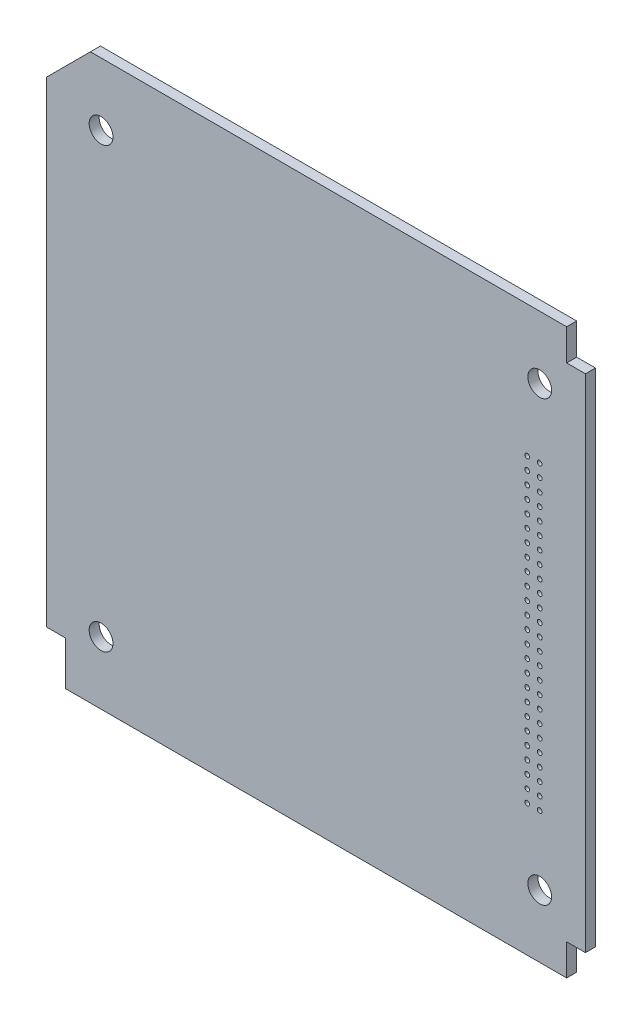
from build123d import *

# Parameters (mm, degrees)
SKETCH1_R           = 1.9
SKETCH1_R_2         = 0.375
SKETCH1_R_3         = 0.383755901
SKETCH1_R_4         = 0.384163196
SKETCH1_R_5         = 0.380771211
SKETCH1_R_6         = 0.377379225
SKETCH1_R_7         = 0.380832793
BOSS_EXTRUDE1_DEPTH = 1.6
SKETCH_1_W          = 3
SKETCH_1_H          = 7
CUT_EXTRUDE_1_DEPTH = 10


with BuildPart() as part:
    # Sketch1 → Boss-Extrude1 (new body)
    with BuildSketch(Plane.XY):
        Polygon((-3, 0), (-86, 0), (-86, -90), (-3, -90), (-3, -85), (0, -85), (0, -5), (-3, -5), align=None)
        with Locations((-7.3, -10)):
            Circle(SKETCH1_R, mode=Mode.SUBTRACT)
        with Locations((-77.3, -10)):
            Circle(SKETCH1_R, mode=Mode.SUBTRACT)
        with Locations((-77.3, -80)):
            Circle(SKETCH1_R, mode=Mode.SUBTRACT)
        with Locations((-7.3, -80)):
            Circle(SKETCH1_R, mode=Mode.SUBTRACT)
        with Locations((-9.3, -69)):
            Circle(SKETCH1_R_2, mode=Mode.SUBTRACT)
        with Locations((-7.3, -69)):
            Circle(SKETCH1_R_2, mode=Mode.SUBTRACT)
        with Locations((-7.3, -67)):
            Circle(SKETCH1_R_2, mode=Mode.SUBTRACT)
        with Locations((-9.3, -67)):
            Circle(SKETCH1_R_2, mode=Mode.SUBTRACT)
        with Locations((-9.3, -65)):
            Circle(SKETCH1_R_2, mode=Mode.SUBTRACT)
        with Locations((-7.3, -65)):
            Circle(SKETCH1_R_2, mode=Mode.SUBTRACT)
        with Locations((-7.3, -63)):
            Circle(SKETCH1_R_2, mode=Mode.SUBTRACT)
        with Locations((-9.3, -63)):
            Circle(SKETCH1_R_3, mode=Mode.SUBTRACT)
        with Locations((-9.3, -61)):
            Circle(SKETCH1_R_2, mode=Mode.SUBTRACT)
        with Locations((-7.3, -61)):
            Circle(SKETCH1_R_2, mode=Mode.SUBTRACT)
        with Locations((-7.3, -59)):
            Circle(SKETCH1_R_2, mode=Mode.SUBTRACT)
        with Locations((-9.3, -59)):
            Circle(SKETCH1_R_2, mode=Mode.SUBTRACT)
        with Locations((-7.3, -57)):
            Circle(SKETCH1_R_2, mode=Mode.SUBTRACT)
        with Locations((-9.3, -57)):
            Circle(SKETCH1_R_2, mode=Mode.SUBTRACT)
        with Locations((-9.3, -55)):
            Circle(SKETCH1_R_2, mode=Mode.SUBTRACT)
        with Locations((-7.3, -55)):
            Circle(SKETCH1_R_2, mode=Mode.SUBTRACT)
        with Locations((-7.3, -53)):
            Circle(SKETCH1_R_2, mode=Mode.SUBTRACT)
        with Locations((-9.3, -53)):
            Circle(SKETCH1_R_2, mode=Mode.SUBTRACT)
        with Locations((-9.3, -51)):
            Circle(SKETCH1_R_2, mode=Mode.SUBTRACT)
        with Locations((-7.3, -51)):
            Circle(SKETCH1_R_2, mode=Mode.SUBTRACT)
        with Locations((-7.3, -49)):
            Circle(SKETCH1_R_2, mode=Mode.SUBTRACT)
        with Locations((-9.3, -49)):
            Circle(SKETCH1_R_2, mode=Mode.SUBTRACT)
        with Locations((-9.3, -47)):
            Circle(SKETCH1_R_2, mode=Mode.SUBTRACT)
        with Locations((-7.3, -47)):
            Circle(SKETCH1_R_2, mode=Mode.SUBTRACT)
        with Locations((-7.3, -45)):
            Circle(SKETCH1_R_2, mode=Mode.SUBTRACT)
        with Locations((-9.3, -45)):
            Circle(SKETCH1_R_4, mode=Mode.SUBTRACT)
        with Locations((-9.3, -43)):
            Circle(SKETCH1_R_2, mode=Mode.SUBTRACT)
        with Locations((-7.3, -43)):
            Circle(SKETCH1_R_5, mode=Mode.SUBTRACT)
        with Locations((-7.3, -41)):
            Circle(SKETCH1_R_6, mode=Mode.SUBTRACT)
        with Locations((-9.3, -41)):
            Circle(SKETCH1_R_6, mode=Mode.SUBTRACT)
        with Locations((-9.3, -39)):
            Circle(SKETCH1_R_2, mode=Mode.SUBTRACT)
        with Locations((-7.3, -39)):
            Circle(SKETCH1_R_2, mode=Mode.SUBTRACT)
        with Locations((-7.3, -37)):
            Circle(SKETCH1_R_2, mode=Mode.SUBTRACT)
        with Locations((-9.3, -37)):
            Circle(SKETCH1_R_7, mode=Mode.SUBTRACT)
        with Locations((-7.3, -35)):
            Circle(SKETCH1_R_2, mode=Mode.SUBTRACT)
        with Locations((-9.3, -35)):
            Circle(SKETCH1_R_2, mode=Mode.SUBTRACT)
        with Locations((-9.3, -33)):
            Circle(SKETCH1_R_2, mode=Mode.SUBTRACT)
        with Locations((-7.3, -33)):
            Circle(SKETCH1_R_2, mode=Mode.SUBTRACT)
        with Locations((-7.3, -31)):
            Circle(SKETCH1_R_2, mode=Mode.SUBTRACT)
        with Locations((-9.3, -31)):
            Circle(SKETCH1_R_2, mode=Mode.SUBTRACT)
        with Locations((-7.3, -29)):
            Circle(SKETCH1_R_2, mode=Mode.SUBTRACT)
        with Locations((-9.3, -29)):
            Circle(SKETCH1_R_2, mode=Mode.SUBTRACT)
        with Locations((-9.3, -27)):
            Circle(SKETCH1_R_2, mode=Mode.SUBTRACT)
        with Locations((-7.3, -27)):
            Circle(SKETCH1_R_2, mode=Mode.SUBTRACT)
        with Locations((-7.3, -25)):
            Circle(SKETCH1_R_2, mode=Mode.SUBTRACT)
        with Locations((-9.3, -25)):
            Circle(SKETCH1_R_2, mode=Mode.SUBTRACT)
        with Locations((-7.3, -23)):
            Circle(SKETCH1_R_2, mode=Mode.SUBTRACT)
        with Locations((-9.3, -23)):
            Circle(SKETCH1_R_2, mode=Mode.SUBTRACT)
        with Locations((-9.3, -21)):
            Circle(SKETCH1_R_2, mode=Mode.SUBTRACT)
        with Locations((-7.3, -21)):
            Circle(SKETCH1_R_2, mode=Mode.SUBTRACT)
    extrude(amount=BOSS_EXTRUDE1_DEPTH)

    # ｽｹｯﾁ1 → ｶｯﾄ - 押し出し1 (cut)
    with BuildSketch(Plane.XY.offset(1.6)):
        with Locations((-84.5, -86.5)):
            Rectangle(SKETCH_1_W, SKETCH_1_H)
        Polygon((-86, 0), (-86, -7), (-79, 0), align=None)
    extrude(amount=-CUT_EXTRUDE_1_DEPTH, mode=Mode.SUBTRACT)


solid = part.part
